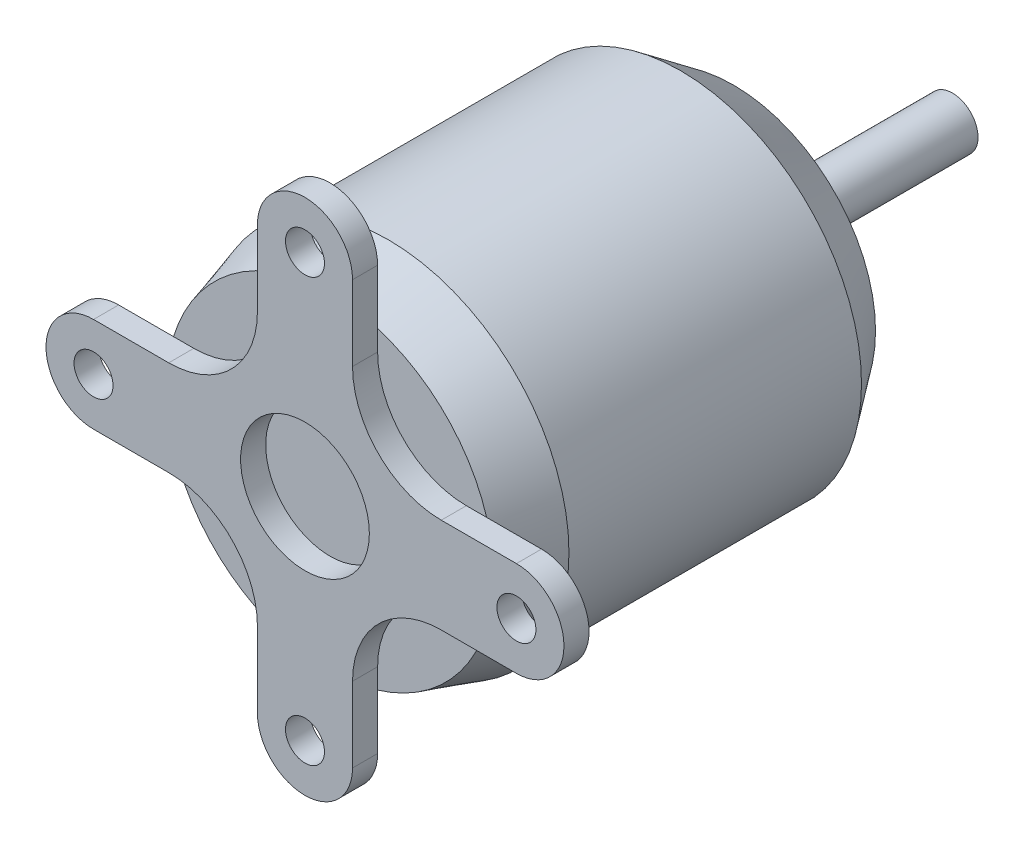
from build123d import *

# Parameters (mm, degrees)
SKETCH2_R           = 1.5
BOSS_EXTRUDE1_DEPTH = 1.9304
CIRPATTERN1_COUNT   = 4


with BuildPart() as part:
    # Sketch1 → Revolve1 (revolve)
    with BuildSketch(Plane(origin=(0, 0, 0), x_dir=(0, 0, -1), z_dir=(1, 0, 0))):
        Polygon((0, 0), (0, 12.5857), (4.4704, 13.9065), (26.9748, 13.9065), (31.0388, 10.922), (31.0388, 4.50215), (34.9758, 4.50215), (34.9758, 1.9685), (47.879, 1.9685), (47.879, 0), align=None)
    revolve(axis=Axis((0, 0, 0), (0, 0, 1)))

    # Sketch2 → Boss-Extrude1 (add)
    with BuildSketch(Plane.XY):
        with BuildLine():
            Line((-3.6576, 12.04250002), (-3.6576, 10.483480973))
            Line((-3.6576, 10.483480973), (-3.6576, 3.6576))
            Line((-3.6576, 3.6576), (-3.502299887, 3.502299887))
            ThreePointArc((-3.502299887, 3.502299887), (0, 4.953), (3.502299887, 3.502299887))
            Line((3.502299887, 3.502299887), (3.6576, 3.6576))
            Line((3.6576, 3.6576), (3.6576, 10.483480973))
            Line((3.6576, 10.483480973), (3.6576, 12.04250002))
            ThreePointArc((3.6576, 12.04250002), (0, 12.5857), (-3.6576, 12.04250002))
        make_face()
        with BuildLine():
            Line((-3.6576, 3.6576), (-3.6576, 10.483480973))
            ThreePointArc((-3.6576, 10.483480973), (-4.177189251, 7.871329413), (-5.656854249, 5.656854249))
            Line((-5.656854249, 5.656854249), (-3.6576, 3.6576))
        make_face()
        with BuildLine():
            ThreePointArc((5.656854249, 5.656854249), (4.177189251, 7.871329413), (3.6576, 10.483480973))
            Line((3.6576, 10.483480973), (3.6576, 3.6576))
            Line((3.6576, 3.6576), (5.656854249, 5.656854249))
        make_face()
        with BuildLine():
            Line((-3.6576, 16.265), (-3.6576, 12.04250002))
            ThreePointArc((-3.6576, 12.04250002), (0, 12.5857), (3.6576, 12.04250002))
            Line((3.6576, 12.04250002), (3.6576, 16.265))
            ThreePointArc((3.6576, 16.265), (0, 19.9226), (-3.6576, 16.265))
        make_face()
        with Locations((0, 16.265)):
            Circle(SKETCH2_R, mode=Mode.SUBTRACT)
    boss_extrude1 = extrude(amount=BOSS_EXTRUDE1_DEPTH)

    # CirPattern1: Boss-Extrude1 ×4 about axis
    cirpattern1_axis = Axis((0, 0, 0), (0, 0, 1))
    for i in range(1, CIRPATTERN1_COUNT):
        add(boss_extrude1.rotate(cirpattern1_axis, i * 360 / CIRPATTERN1_COUNT))


solid = part.part
